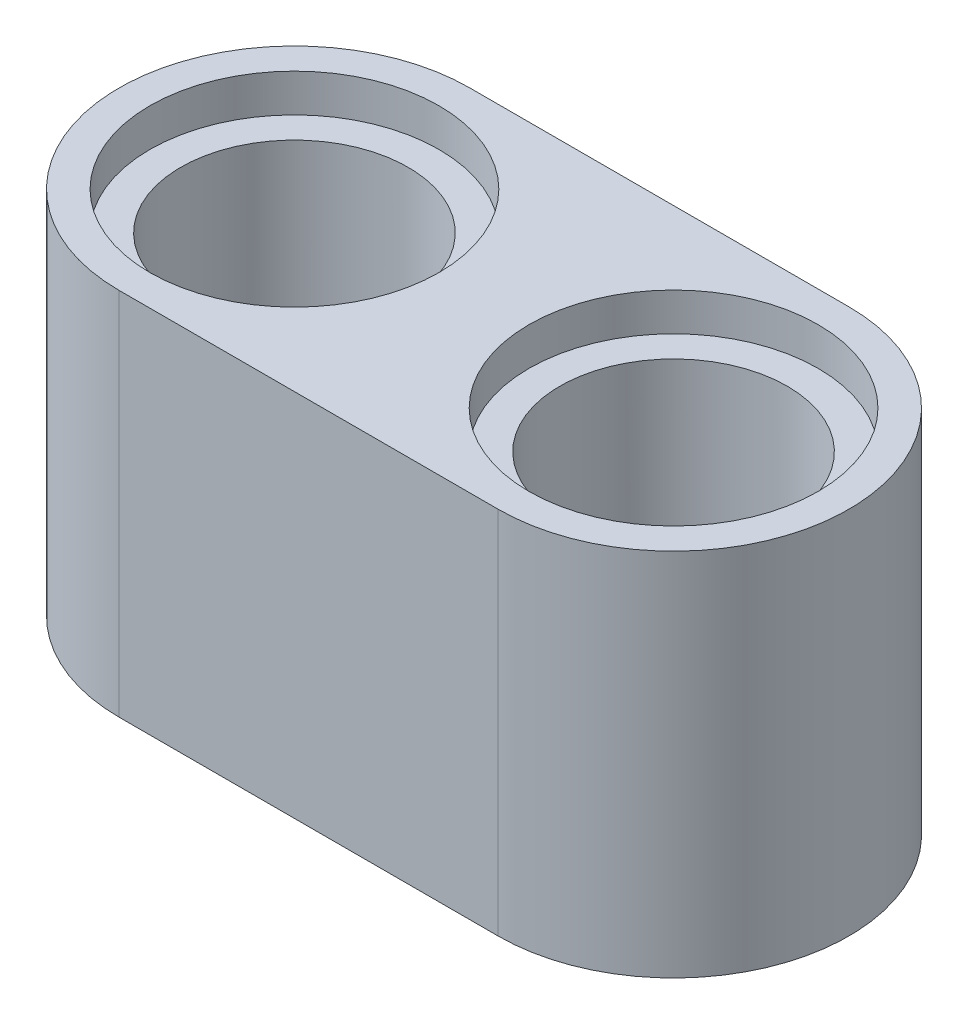
from build123d import *

# Parameters (mm, degrees)
BOSS_EXTRUDE3_DEPTH = 7.8
SKETCH2_R           = 2.4
CUT_EXTRUDE6_DEPTH  = 7.8
SKETCH3_R           = 3.05
CUT_EXTRUDE7_DEPTH  = 0.8
SKETCH4_R           = 3.05
CUT_EXTRUDE8_DEPTH  = 0.8


with BuildPart() as part:
    # Sketch1 → Boss-Extrude3 (new body)
    with BuildSketch(Plane(origin=(0, 0, 0), x_dir=(1, 0, 0), z_dir=(0, 1, 0))):
        with BuildLine():
            Line((-16, 3.7), (-8, 3.7))
            ThreePointArc((-8, 3.7), (-4.3, 0), (-8, -3.7))
            Line((-8, -3.7), (-16, -3.7))
            ThreePointArc((-16, -3.7), (-19.7, 0), (-16, 3.7))
        make_face()
    extrude(amount=BOSS_EXTRUDE3_DEPTH)

    # Sketch2 → Cut-Extrude6 (cut)
    with BuildSketch(Plane(origin=(0, 7.8, 0), x_dir=(1, 0, 0), z_dir=(0, 1, 0))):
        with Locations((-16, 0)):
            Circle(SKETCH2_R)
        with Locations((-8, 0)):
            Circle(SKETCH2_R)
    extrude(amount=-CUT_EXTRUDE6_DEPTH, mode=Mode.SUBTRACT)

    # Sketch3 → Cut-Extrude7 (cut)
    with BuildSketch(Plane(origin=(0, 7.8, 0), x_dir=(1, 0, 0), z_dir=(0, 1, 0))):
        with Locations((-16, 0)):
            Circle(SKETCH3_R)
        with Locations((-8, 0)):
            Circle(SKETCH3_R)
    extrude(amount=-CUT_EXTRUDE7_DEPTH, mode=Mode.SUBTRACT)

    # Sketch4 → Cut-Extrude8 (cut)
    with BuildSketch(Plane.XZ):
        with Locations((-16, 0)):
            Circle(SKETCH4_R)
        with Locations((-8, 0)):
            Circle(SKETCH4_R)
    extrude(amount=-CUT_EXTRUDE8_DEPTH, mode=Mode.SUBTRACT)


solid = part.part
